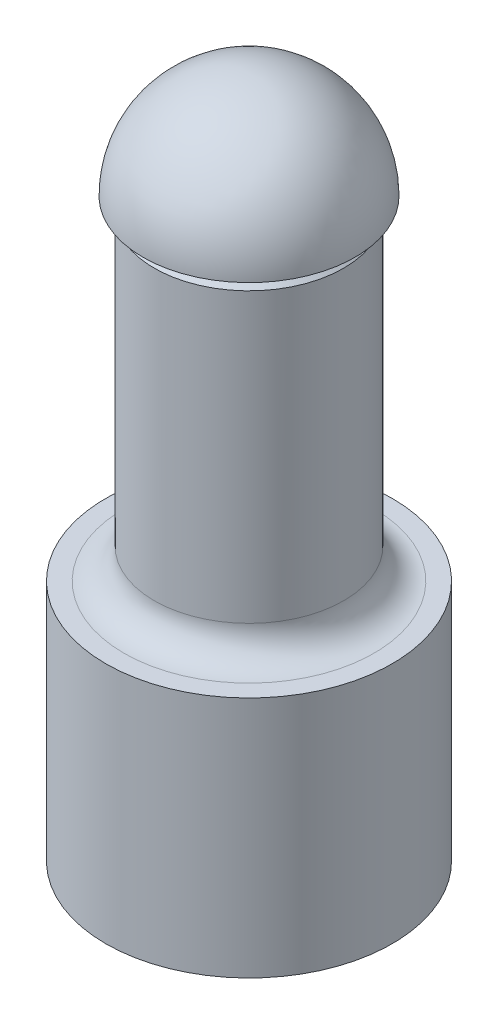
from build123d import *

# Parameters (mm, degrees)
SKETCH1_R               = 6.25
BOSS_EXTRUDE1_DEPTH     = 38
SKETCH1_3_R             = 9.45
BOSS_EXTRUDE2_DEPTH     = 16
FILLET1_R               = 2
CHAMFER1_SIZE           = 1
CUT_EXTRUDE4_START      = 6.35
CUT_EXTRUDE4_DEPTH      = 6.35
CUT_EXTRUDE5_DEPTH      = 12.7
CUT_EXTRUDE6_REACH      = 50.199
CUT_EXTRUDE6_END_RADIUS = 9.45
SKETCH6_R               = 1.25


with BuildPart() as part:
    # Sketch1 → Boss-Extrude1 (new body)
    with BuildSketch(Plane(origin=(0, 0, 0), x_dir=(1, 0, 0), z_dir=(0, 1, 0))):
        Circle(SKETCH1_R)
    extrude(amount=BOSS_EXTRUDE1_DEPTH)

    # Sketch1_3 → Boss-Extrude2 (add)
    with BuildSketch(Plane(origin=(0, 0, 0), x_dir=(1, 0, 0), z_dir=(0, 1, 0))):
        Circle(SKETCH1_3_R)
    extrude(amount=BOSS_EXTRUDE2_DEPTH)

    # Fillet1
    fillet1_edges = [part.edges().sort_by_distance(p)[0] for p in [
        (-6.25, 16, 0),
    ]]
    fillet(fillet1_edges, radius=FILLET1_R)

    # Chamfer1
    chamfer1_edges = [part.edges().sort_by_distance(p)[0] for p in [
        (-6.25, 38, 0),
    ]]
    chamfer(chamfer1_edges, length=CHAMFER1_SIZE)

    # Sketch2 → Revolve1 (revolve)
    with BuildSketch(Plane(origin=(0, 0, 0), x_dir=(0, 0, -1), z_dir=(1, 0, 0))):
        with BuildLine():
            Line((0, 45), (0, 38))
            Line((0, 38), (7, 38))
            ThreePointArc((7, 38), (4.949747468, 42.949747468), (0, 45))
        make_face()
    revolve(axis=Axis((0, 47.571975937, 0), (0, -1, 0)))

    # Sketch3 → Cut-Extrude4 (cut)
    with BuildSketch(Plane(origin=(0, 38, 0), x_dir=(-1, 0, 0), z_dir=(0, -1, 0)).offset(CUT_EXTRUDE4_START)):
        with BuildLine():
            Line((-3.75, 5), (3.75, 5))
            ThreePointArc((3.75, 5), (0, 6.25), (-3.75, 5))
        make_face()
    extrude(amount=-CUT_EXTRUDE4_DEPTH, mode=Mode.SUBTRACT)

    # Sketch5 → Cut-Extrude5 (cut)
    with BuildSketch(Plane.XZ):
        with BuildLine():
            Line((4.153311931, -5), (-4.153311931, -5))
            ThreePointArc((-4.153311931, -5), (0, 6.5), (4.153311931, -5))
        make_face()
    extrude(amount=-CUT_EXTRUDE5_DEPTH, mode=Mode.SUBTRACT)

    # Cut-Extrude6: up to this cylinder (the profile starts inside it)
    cut_extrude6_end = Plane(origin=(0, 6.35, 0), z_dir=(0, -1, 0)) * Cylinder(CUT_EXTRUDE6_END_RADIUS, 120.298, mode=Mode.PRIVATE)
    # Sketch6 → Cut-Extrude6 (cut, up to the surface)
    with BuildSketch(Plane.XY.offset(-5), mode=Mode.PRIVATE) as cut_extrude6_sk1:
        with Locations((0, 6.35)):
            Circle(SKETCH6_R)
    cut_extrude6_tool1 = extrude(cut_extrude6_sk1.sketch, amount=-CUT_EXTRUDE6_REACH, mode=Mode.PRIVATE) & cut_extrude6_end
    add(cut_extrude6_tool1.solids().sort_by_distance((0, 6.35, -5))[0], mode=Mode.SUBTRACT)


solid = part.part
